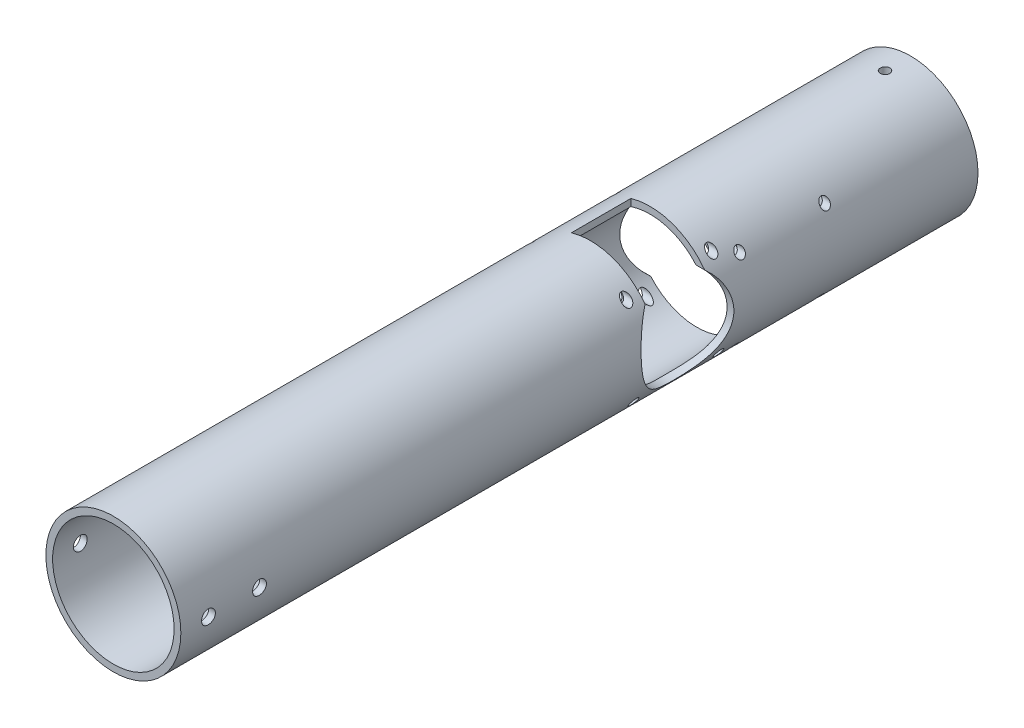
from build123d import *

# Parameters (mm, degrees)
SKETCH1_R                     = 31.75
SKETCH1_R_2                   = 28.575
BOSS_EXTRUDE1_DEPTH           = 125
BOSS_EXTRUDE1_DEPTH_BACK      = 250
SKETCH2_R                     = 21.75
CUT_EXTRUDE1_DEPTH            = 32.75
SKETCH3_R                     = 21.75
CUT_EXTRUDE2_DEPTH            = 32.7500001
CUT_EXTRUDE4_START            = 9
SKETCH5_W                     = 28
SKETCH5_H                     = 22
CUT_EXTRUDE4_DEPTH            = 41.750000101
CUT_EXTRUDE5_START            = -9
SKETCH6_W                     = 28
SKETCH6_H                     = 22
CUT_EXTRUDE5_DEPTH            = 41.7500001
SKETCH11_R                    = 2
CUT_EXTRUDE8_DEPTH            = 32.7500001
CUT_EXTRUDE8_DEPTH_BACK       = 32.750000101
SKETCH12_R                    = 3.25
CUT_EXTRUDE10_DEPTH           = 32.7500001
CUT_EXTRUDE10_DEPTH_BACK      = 32.750000101
SKETCH13_R                    = 2.25
CUT_EXTRUDE11_DEPTH           = 32.7500001
CUT_EXTRUDE11_DEPTH_BACK      = 32.7500001
SKETCH15_R                    = 2
CUT_EXTRUDE12_DEPTH           = 32.7500001
CUT_EXTRUDE12_DEPTH_BACK      = 32.750000101
SKETCH19_W                    = 2.25
SKETCH19_H                    = 31.75
M4_CLEARANCE_HOLE1_AT_2_COUNT = 2
M4_CLEARANCE_HOLE1_AT_2_PITCH = 40
M4_CLEARANCE_HOLE1_AT_3_COUNT = 2
M4_CLEARANCE_HOLE1_AT_3_PITCH = 40
M4_CLEARANCE_HOLE1_AT_4_COUNT = 2
M4_CLEARANCE_HOLE1_AT_4_PITCH = 56.568542495
M4_CLEARANCE_HOLE1_AT_5_COUNT = 2
M4_CLEARANCE_HOLE1_AT_5_PITCH = 90.126807577
M4_CLEARANCE_HOLE1_AT_6_COUNT = 2
M4_CLEARANCE_HOLE1_AT_6_PITCH = 50.197623888
M4_CLEARANCE_HOLE1_AT_7_COUNT = 2
M4_CLEARANCE_HOLE1_AT_7_PITCH = 100.213978286
M4_CLEARANCE_HOLE1_AT_8_COUNT = 2
M4_CLEARANCE_HOLE1_AT_8_PITCH = 66.631835064
MIRROR1_COPY_1_SKETCH_W       = 2.25
MIRROR1_COPY_1_SKETCH_H       = 31.75
MIRROR1_COPY_2_SKETCH_W       = 2.25
MIRROR1_COPY_2_SKETCH_H       = 31.75
MIRROR1_COPY_3_SKETCH_W       = 2.25
MIRROR1_COPY_3_SKETCH_H       = 31.75
MIRROR1_COPY_4_SKETCH_W       = 2.25
MIRROR1_COPY_4_SKETCH_H       = 31.75
MIRROR1_COPY_5_SKETCH_W       = 2.25
MIRROR1_COPY_5_SKETCH_H       = 31.75
MIRROR1_COPY_6_SKETCH_W       = 2.25
MIRROR1_COPY_6_SKETCH_H       = 31.75
MIRROR1_COPY_7_SKETCH_W       = 2.25
MIRROR1_COPY_7_SKETCH_H       = 31.75


with BuildPart() as part:
    # Sketch1 → Boss-Extrude1 (new body, two sides)
    with BuildSketch(Plane.XY) as boss_extrude1_sk:
        Circle(SKETCH1_R)
        Circle(SKETCH1_R_2, mode=Mode.SUBTRACT)
    extrude(amount=BOSS_EXTRUDE1_DEPTH)
    extrude(boss_extrude1_sk.sketch, amount=-BOSS_EXTRUDE1_DEPTH_BACK)

    # Sketch2 → Cut-Extrude1 (cut, through all)
    with BuildSketch(Plane(origin=(0, 0, 0), x_dir=(0, 0, -1), z_dir=(1, 0, 0))):
        with Locations((163.488, -2)):
            Circle(SKETCH2_R)
    extrude(amount=-CUT_EXTRUDE1_DEPTH, mode=Mode.SUBTRACT)

    # Sketch3 → Cut-Extrude2 (cut, through all)
    with BuildSketch(Plane(origin=(0, 0, 0), x_dir=(0, 0, -1), z_dir=(1, 0, 0))):
        with Locations((113.45, 2)):
            Circle(SKETCH3_R)
    extrude(amount=CUT_EXTRUDE2_DEPTH, mode=Mode.SUBTRACT)

    # Sketch5 → Cut-Extrude4 (cut, through all)
    with BuildSketch(Plane(origin=(0, 0, 0), x_dir=(0, 0, -1), z_dir=(1, 0, 0)).offset(CUT_EXTRUDE4_START)):
        with Locations((163.488, -23.75)):
            Rectangle(SKETCH5_W, SKETCH5_H)
    extrude(amount=-CUT_EXTRUDE4_DEPTH, mode=Mode.SUBTRACT)

    # Sketch6 → Cut-Extrude5 (cut, through all)
    with BuildSketch(Plane(origin=(0, 0, 0), x_dir=(0, 0, -1), z_dir=(1, 0, 0)).offset(CUT_EXTRUDE5_START)):
        with Locations((113.45, 23.75)):
            Rectangle(SKETCH6_W, SKETCH6_H)
    extrude(amount=CUT_EXTRUDE5_DEPTH, mode=Mode.SUBTRACT)

    # Sketch11 → Cut-Extrude8 (cut, two sides)
    with BuildSketch(Plane(origin=(0, 0, 0), x_dir=(0, 0, -1), z_dir=(1, 0, 0))) as cut_extrude8_sk:
        with Locations((183.488, 18)):
            Circle(SKETCH11_R)
        with Locations((143.488, 18)):
            Circle(SKETCH11_R)
        with Locations((143.488, -22)):
            Circle(SKETCH11_R)
        with Locations((183.488, -22)):
            Circle(SKETCH11_R)
    extrude(amount=CUT_EXTRUDE8_DEPTH, mode=Mode.SUBTRACT)
    extrude(cut_extrude8_sk.sketch, amount=-CUT_EXTRUDE8_DEPTH_BACK, mode=Mode.SUBTRACT)

    # Sketch12 → Cut-Extrude10 (cut, two sides)
    with BuildSketch(Plane(origin=(0, 0, 0), x_dir=(0, 0, -1), z_dir=(1, 0, 0))) as cut_extrude10_sk:
        with Locations((-112, 0)):
            Circle(SKETCH12_R)
        with Locations((-88, 0)):
            Circle(SKETCH12_R)
    extrude(amount=CUT_EXTRUDE10_DEPTH, mode=Mode.SUBTRACT)
    extrude(cut_extrude10_sk.sketch, amount=-CUT_EXTRUDE10_DEPTH_BACK, mode=Mode.SUBTRACT)

    # Sketch13 → Cut-Extrude11 (cut, two sides)
    with BuildSketch(Plane(origin=(0, 0, 0), x_dir=(1, 0, 0), z_dir=(0, 1, 0))) as cut_extrude11_sk:
        with Locations((0, 238)):
            Circle(SKETCH13_R)
    extrude(amount=CUT_EXTRUDE11_DEPTH, mode=Mode.SUBTRACT)
    extrude(cut_extrude11_sk.sketch, amount=-CUT_EXTRUDE11_DEPTH_BACK, mode=Mode.SUBTRACT)

    # Sketch15 → Cut-Extrude12 (cut, two sides)
    with BuildSketch(Plane(origin=(0, 0, 0), x_dir=(0, 0, -1), z_dir=(1, 0, 0))) as cut_extrude12_sk:
        with Locations((93.45, 22)):
            Circle(SKETCH15_R)
        with Locations((133.45, 22)):
            Circle(SKETCH15_R)
        with Locations((133.45, -18)):
            Circle(SKETCH15_R)
        with Locations((93.45, -18)):
            Circle(SKETCH15_R)
    extrude(amount=CUT_EXTRUDE12_DEPTH, mode=Mode.SUBTRACT)
    extrude(cut_extrude12_sk.sketch, amount=-CUT_EXTRUDE12_DEPTH_BACK, mode=Mode.SUBTRACT)

    # Sketch19 → M4 Clearance Hole1 (revolve, cut)
    with BuildSketch(Plane(origin=(0, 22, -93.45), x_dir=(0, 0, 1), z_dir=(0, 1, 0))):
        with Locations((1.125, 15.875)):
            Rectangle(SKETCH19_W, SKETCH19_H)
    m4_clearance_hole1 = revolve(axis=Axis((-6.35, 22, -93.45), (1, 0, 0)), mode=Mode.SUBTRACT)

    # M4 Clearance Hole1 at 2: M4 Clearance Hole1 ×2
    with Locations(*[(0, 0, -i * M4_CLEARANCE_HOLE1_AT_2_PITCH) for i in range(1, M4_CLEARANCE_HOLE1_AT_2_COUNT)]):
        add(m4_clearance_hole1, mode=Mode.SUBTRACT)

    # M4 Clearance Hole1 at 3: M4 Clearance Hole1 ×2
    with Locations(*[(0, -i * M4_CLEARANCE_HOLE1_AT_3_PITCH, 0) for i in range(1, M4_CLEARANCE_HOLE1_AT_3_COUNT)]):
        add(m4_clearance_hole1, mode=Mode.SUBTRACT)

    # M4 Clearance Hole1 at 4: M4 Clearance Hole1 ×2
    with Locations(*[Vector(0, -0.707106781, -0.707106781) * (i * M4_CLEARANCE_HOLE1_AT_4_PITCH) for i in range(1, M4_CLEARANCE_HOLE1_AT_4_COUNT)]):
        add(m4_clearance_hole1, mode=Mode.SUBTRACT)

    # M4 Clearance Hole1 at 5: M4 Clearance Hole1 ×2
    with Locations(*[Vector(0, -0.044381912, -0.999014637) * (i * M4_CLEARANCE_HOLE1_AT_5_PITCH) for i in range(1, M4_CLEARANCE_HOLE1_AT_5_COUNT)]):
        add(m4_clearance_hole1, mode=Mode.SUBTRACT)

    # M4 Clearance Hole1 at 6: M4 Clearance Hole1 ×2
    with Locations(*[Vector(0, -0.079685047, -0.996820091) * (i * M4_CLEARANCE_HOLE1_AT_6_PITCH) for i in range(1, M4_CLEARANCE_HOLE1_AT_6_COUNT)]):
        add(m4_clearance_hole1, mode=Mode.SUBTRACT)

    # M4 Clearance Hole1 at 7: M4 Clearance Hole1 ×2
    with Locations(*[Vector(0, -0.439060506, -0.898457496) * (i * M4_CLEARANCE_HOLE1_AT_7_PITCH) for i in range(1, M4_CLEARANCE_HOLE1_AT_7_COUNT)]):
        add(m4_clearance_hole1, mode=Mode.SUBTRACT)

    # M4 Clearance Hole1 at 8: M4 Clearance Hole1 ×2
    with Locations(*[Vector(0, -0.660345013, -0.750962358) * (i * M4_CLEARANCE_HOLE1_AT_8_PITCH) for i in range(1, M4_CLEARANCE_HOLE1_AT_8_COUNT)]):
        add(m4_clearance_hole1, mode=Mode.SUBTRACT)

    # Mirror1: M4 Clearance Hole1 across plane
    add(m4_clearance_hole1.mirror(Plane(origin=(0, 0, 0), x_dir=(0, 0, 1), z_dir=(1, 0, 0))), mode=Mode.SUBTRACT)

    # Mirror1 copy 1 sketch → Mirror1 copy 1 (revolve, cut)
    with BuildSketch(Plane(origin=(0, 22, -133.45), x_dir=(0, 0, 1), z_dir=(0, 1, 0))):
        with Locations((1.125, -15.875)):
            Rectangle(MIRROR1_COPY_1_SKETCH_W, MIRROR1_COPY_1_SKETCH_H)
    revolve(axis=Axis((6.35, 22, -133.45), (1, 0, 0)), mode=Mode.SUBTRACT)

    # Mirror1 copy 2 sketch → Mirror1 copy 2 (revolve, cut)
    with BuildSketch(Plane(origin=(0, -18, -93.45), x_dir=(0, 0, 1), z_dir=(0, 1, 0))):
        with Locations((1.125, -15.875)):
            Rectangle(MIRROR1_COPY_2_SKETCH_W, MIRROR1_COPY_2_SKETCH_H)
    revolve(axis=Axis((6.35, -18, -93.45), (1, 0, 0)), mode=Mode.SUBTRACT)

    # Mirror1 copy 3 sketch → Mirror1 copy 3 (revolve, cut)
    with BuildSketch(Plane(origin=(0, -18, -133.45), x_dir=(0, 0, 1), z_dir=(0, 1, 0))):
        with Locations((1.125, -15.875)):
            Rectangle(MIRROR1_COPY_3_SKETCH_W, MIRROR1_COPY_3_SKETCH_H)
    revolve(axis=Axis((6.35, -18, -133.45), (1, 0, 0)), mode=Mode.SUBTRACT)

    # Mirror1 copy 4 sketch → Mirror1 copy 4 (revolve, cut)
    with BuildSketch(Plane(origin=(0, 18, -183.488), x_dir=(0, 0, 1), z_dir=(0, 1, 0))):
        with Locations((1.125, -15.875)):
            Rectangle(MIRROR1_COPY_4_SKETCH_W, MIRROR1_COPY_4_SKETCH_H)
    revolve(axis=Axis((6.35, 18, -183.488), (1, 0, 0)), mode=Mode.SUBTRACT)

    # Mirror1 copy 5 sketch → Mirror1 copy 5 (revolve, cut)
    with BuildSketch(Plane(origin=(0, 18, -143.488), x_dir=(0, 0, 1), z_dir=(0, 1, 0))):
        with Locations((1.125, -15.875)):
            Rectangle(MIRROR1_COPY_5_SKETCH_W, MIRROR1_COPY_5_SKETCH_H)
    revolve(axis=Axis((6.35, 18, -143.488), (1, 0, 0)), mode=Mode.SUBTRACT)

    # Mirror1 copy 6 sketch → Mirror1 copy 6 (revolve, cut)
    with BuildSketch(Plane(origin=(0, -22, -183.488), x_dir=(0, 0, 1), z_dir=(0, 1, 0))):
        with Locations((1.125, -15.875)):
            Rectangle(MIRROR1_COPY_6_SKETCH_W, MIRROR1_COPY_6_SKETCH_H)
    revolve(axis=Axis((6.35, -22, -183.488), (1, 0, 0)), mode=Mode.SUBTRACT)

    # Mirror1 copy 7 sketch → Mirror1 copy 7 (revolve, cut)
    with BuildSketch(Plane(origin=(0, -22, -143.488), x_dir=(0, 0, 1), z_dir=(0, 1, 0))):
        with Locations((1.125, -15.875)):
            Rectangle(MIRROR1_COPY_7_SKETCH_W, MIRROR1_COPY_7_SKETCH_H)
    revolve(axis=Axis((6.35, -22, -143.488), (1, 0, 0)), mode=Mode.SUBTRACT)


solid = part.part
